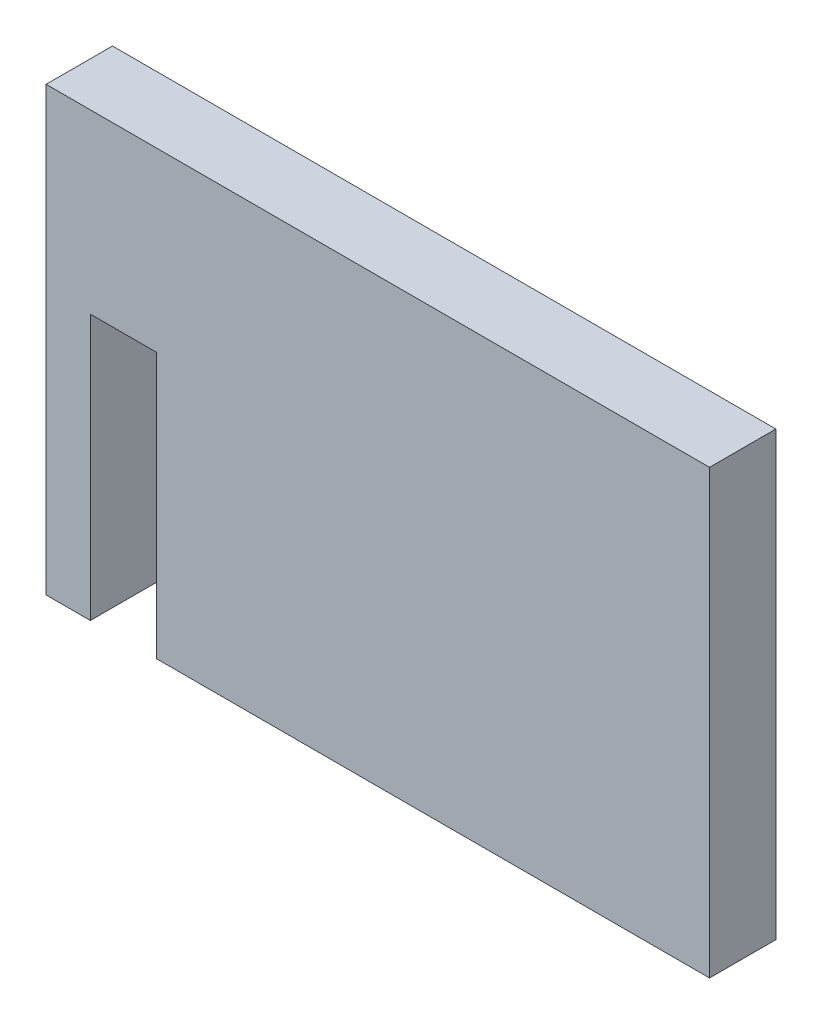
from build123d import *

# Parameters (mm, degrees)
BOSS_EXTRUDE1_DEPTH = 3


with BuildPart() as part:
    # Sketch1 → Boss-Extrude1 (new body)
    with BuildSketch(Plane.XY):
        Polygon((-11.942322376, -10), (13.057677624, -10), (13.057677624, 10), (-16.942322376, 10), (-16.942322376, -10), (-14.942322376, -10), (-14.942322376, 2), (-11.942322376, 2), align=None)
    extrude(amount=BOSS_EXTRUDE1_DEPTH)


solid = part.part
